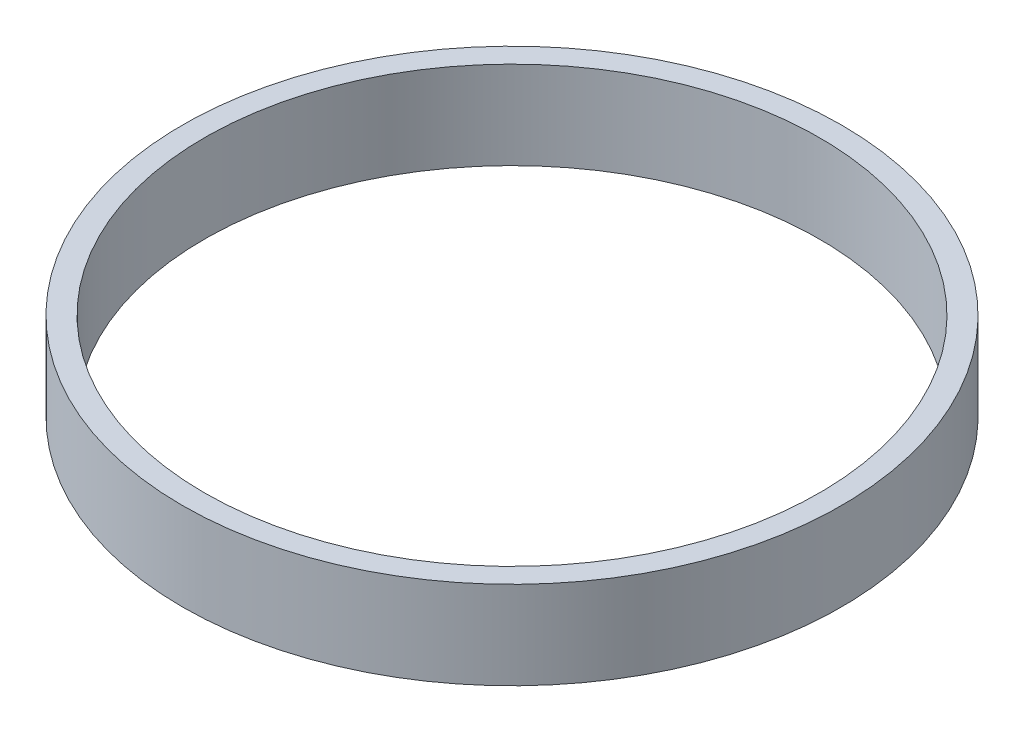
from build123d import *

# Parameters (mm, degrees)
SKETCH1_R           = 37.5
SKETCH1_R_2         = 35
BOSS_EXTRUDE1_DEPTH = 10


with BuildPart() as part:
    # Sketch1 → Boss-Extrude1 (new body)
    with BuildSketch(Plane(origin=(0, 0, 0), x_dir=(1, 0, 0), z_dir=(0, 1, 0))):
        Circle(SKETCH1_R)
        Circle(SKETCH1_R_2, mode=Mode.SUBTRACT)
    extrude(amount=BOSS_EXTRUDE1_DEPTH)


solid = part.part
